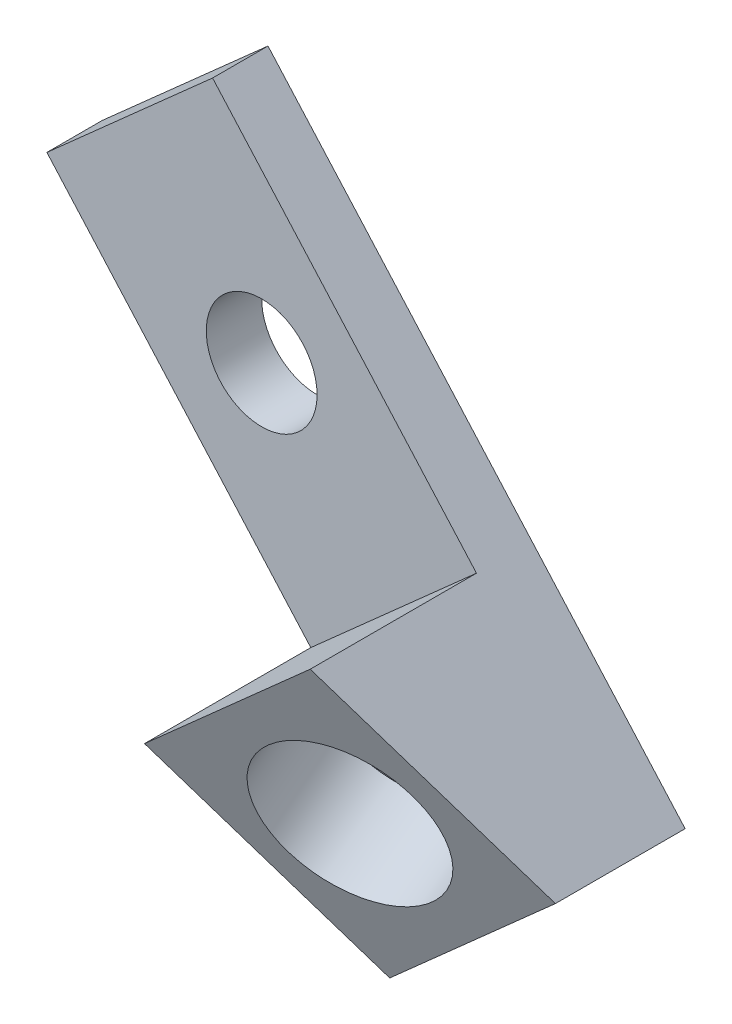
from build123d import *

# Parameters (mm, degrees)
BOSS_EXTRUDE1_DEPTH = 12.7
SKETCH4_R           = 6.35
CUT_EXTRUDE1_DEPTH  = 7.35
SKETCH5_R           = 9.525
CUT_EXTRUDE2_DEPTH  = 11.43


with BuildPart() as part:
    # Sketch3 → Boss-Extrude1 (new body, symmetric)
    with BuildSketch(Plane(origin=(-49.66137931, -44.143448276, 0), x_dir=(0, 0, 1), z_dir=(-0.747409319, -0.664363839, 0))):
        Polygon((0, 292.094644262), (0, 220.157811167), (14.861770509, 220.157811167), (25.4, 246.581936946), (6.35, 246.581936946), (6.35, 292.094644262), align=None)
    extrude(amount=BOSS_EXTRUDE1_DEPTH, both=True)

    # Sketch4 → Cut-Extrude1 (cut, through all)
    with BuildSketch(Plane.XY.offset(6.35)):
        with Locations((-228.6, 157.1625)):
            Circle(SKETCH4_R)
    extrude(amount=-CUT_EXTRUDE1_DEPTH, mode=Mode.SUBTRACT)

    # Sketch5 → Cut-Extrude2 (cut)
    with BuildSketch(Plane(origin=(-16.673775789, 18.757997763, -62.930465953), x_dir=(0.969242963, 0.07030135, -0.235851222), z_dir=(0.246105828, -0.276869057, 0.928857065))):
        with Locations((-193.99687807, 130.601446216)):
            Circle(SKETCH5_R)
    extrude(amount=-CUT_EXTRUDE2_DEPTH, mode=Mode.SUBTRACT)


solid = part.part
